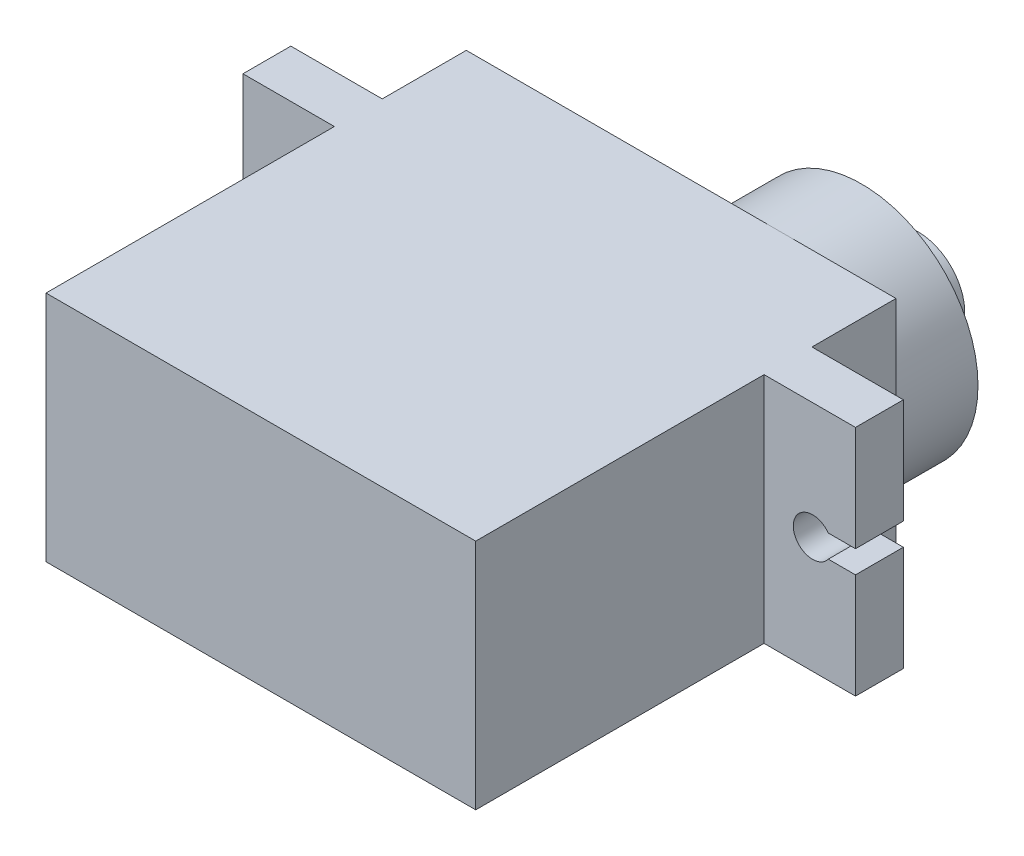
from build123d import *

# Parameters (mm, degrees)
SKETCH1_W           = 22.8
SKETCH1_H           = 22.3
BOSS_EXTRUDE1_DEPTH = 6.175
SKETCH2_W           = 2.54
SKETCH2_H           = 12.35
BOSS_EXTRUDE2_DEPTH = 4.85
CUT_EXTRUDE1_DEPTH  = 18.84
SKETCH4_R           = 6.175
BOSS_EXTRUDE3_DEPTH = 4.35
SKETCH5_R           = 2.475
BOSS_EXTRUDE4_DEPTH = 3
SKETCH6_R           = 0.9
CUT_EXTRUDE2_DEPTH  = 2


with BuildPart() as part:
    # Sketch1 → Boss-Extrude1 (new body, symmetric)
    with BuildSketch(Plane(origin=(0, 0, 0), x_dir=(1, 0, 0), z_dir=(0, 1, 0))):
        Rectangle(SKETCH1_W, SKETCH1_H)
    extrude(amount=BOSS_EXTRUDE1_DEPTH, both=True)

    # Sketch2 → Boss-Extrude2 (add)
    with BuildSketch(Plane(origin=(11.4, 0, 0), x_dir=(0, 0, -1), z_dir=(1, 0, 0))):
        with Locations((5.42, 0)):
            Rectangle(SKETCH2_W, SKETCH2_H)
    boss_extrude2 = extrude(amount=BOSS_EXTRUDE2_DEPTH)

    # Mirror1: Boss-Extrude2 across plane
    add(boss_extrude2.mirror(Plane(origin=(0, 0, 0), x_dir=(0, 0, 1), z_dir=(1, 0, 0))))

    # Sketch3 → Cut-Extrude1 (cut, through all)
    with BuildSketch(Plane(origin=(0, 0, -6.69), x_dir=(-1, 0, 0), z_dir=(0, 0, -1))):
        with BuildLine():
            Line((-14.806038507, 0.6), (-16.25, 0.6))
            Line((-16.25, 0.6), (-16.25, -0.6))
            Line((-16.25, -0.6), (-14.806038507, -0.6))
            ThreePointArc((-14.806038507, -0.6), (-12.95, 0), (-14.806038507, 0.6))
        make_face()
        with BuildLine():
            Line((14.806038507, 0.6), (16.25, 0.6))
            Line((16.25, 0.6), (16.25, -0.6))
            Line((16.25, -0.6), (14.806038507, -0.6))
            ThreePointArc((14.806038507, -0.6), (12.95, 0), (14.806038507, 0.6))
        make_face()
    extrude(amount=-CUT_EXTRUDE1_DEPTH, mode=Mode.SUBTRACT)

    # Sketch4 → Boss-Extrude3 (add)
    with BuildSketch(Plane(origin=(0, 0, -11.15), x_dir=(-1, 0, 0), z_dir=(0, 0, -1))):
        with Locations((-5.225, 0)):
            Circle(SKETCH4_R)
    extrude(amount=BOSS_EXTRUDE3_DEPTH)

    # Sketch5 → Boss-Extrude4 (add)
    with BuildSketch(Plane(origin=(0, 0, -15.5), x_dir=(-1, 0, 0), z_dir=(0, 0, -1))):
        with Locations((-5.225, 0)):
            Circle(SKETCH5_R)
    extrude(amount=BOSS_EXTRUDE4_DEPTH)

    # Sketch6 → Cut-Extrude2 (cut)
    with BuildSketch(Plane(origin=(0, 0, -18.5), x_dir=(-1, 0, 0), z_dir=(0, 0, -1))):
        with Locations((-5.225, 0)):
            Circle(SKETCH6_R)
    extrude(amount=-CUT_EXTRUDE2_DEPTH, mode=Mode.SUBTRACT)


solid = part.part
